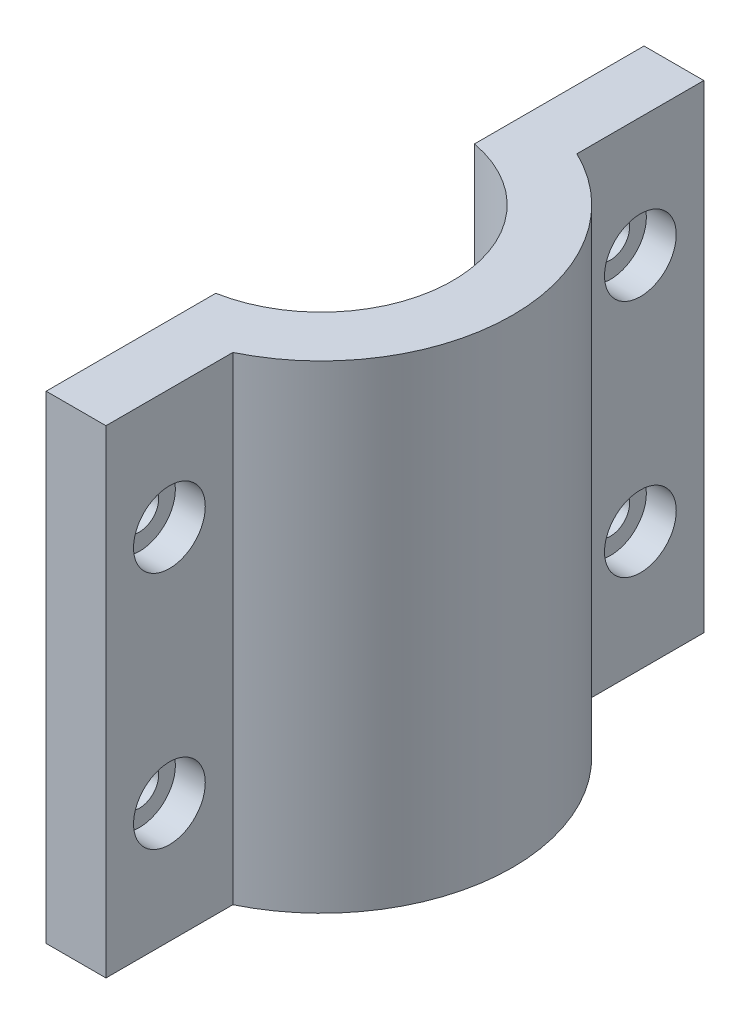
from build123d import *

# Parameters (mm, degrees)
BOSS_EXTRUDE1_DEPTH     = 50.8
SKETCH2_R               = 2.032
CUT_EXTRUDE1_DEPTH      = 12.43
CUT_EXTRUDE1_DEPTH_BACK = 7.35
CUT_EXTRUDE2_START      = -3.175
SKETCH3_R               = 3.81
CUT_EXTRUDE2_DEPTH      = 3.175


with BuildPart() as part:
    # Sketch1 → Boss-Extrude1 (new body)
    with BuildSketch(Plane(origin=(0, 0, 0), x_dir=(1, 0, 0), z_dir=(0, 1, 0))):
        with BuildLine():
            ThreePointArc((6.35, -18.272118104), (17.78, 0), (6.35, 18.272118104))
            Line((6.35, 18.272118104), (6.35, 25.4))
            Line((6.35, 25.4), (6.35, 31.75))
            Line((6.35, 31.75), (0, 31.75))
            Line((0, 31.75), (0, 13.73715036))
            ThreePointArc((0, 13.73715036), (11.43, 0), (0, -13.73715036))
            Line((0, -13.73715036), (0, -31.75))
            Line((0, -31.75), (6.35, -31.75))
            Line((6.35, -31.75), (6.35, -25.4))
            Line((6.35, -25.4), (6.35, -18.272118104))
        make_face()
    extrude(amount=BOSS_EXTRUDE1_DEPTH)

    # Sketch2 → Cut-Extrude1 (cut, two sides)
    with BuildSketch(Plane(origin=(6.35, 0, 0), x_dir=(0, 0, -1), z_dir=(1, 0, 0))) as cut_extrude1_sk:
        with Locations((25.011059052, 38.1)):
            Circle(SKETCH2_R)
        with Locations((25.011059052, 12.7)):
            Circle(SKETCH2_R)
        with Locations((-25.011059052, 12.7)):
            Circle(SKETCH2_R)
        with Locations((-25.011059052, 38.1)):
            Circle(SKETCH2_R)
    extrude(amount=CUT_EXTRUDE1_DEPTH, mode=Mode.SUBTRACT)
    extrude(cut_extrude1_sk.sketch, amount=-CUT_EXTRUDE1_DEPTH_BACK, mode=Mode.SUBTRACT)

    # Sketch3 → Cut-Extrude2 (cut)
    with BuildSketch(Plane(origin=(6.35, 0, 0), x_dir=(0, 0, -1), z_dir=(1, 0, 0)).offset(CUT_EXTRUDE2_START)):
        with Locations((25.011059052, 38.1)):
            Circle(SKETCH3_R)
        with Locations((25.011059052, 12.7)):
            Circle(SKETCH3_R)
        with Locations((-25.011059052, 38.1)):
            Circle(SKETCH3_R)
        with Locations((-25.011059052, 12.7)):
            Circle(SKETCH3_R)
    extrude(amount=CUT_EXTRUDE2_DEPTH, mode=Mode.SUBTRACT)


solid = part.part
